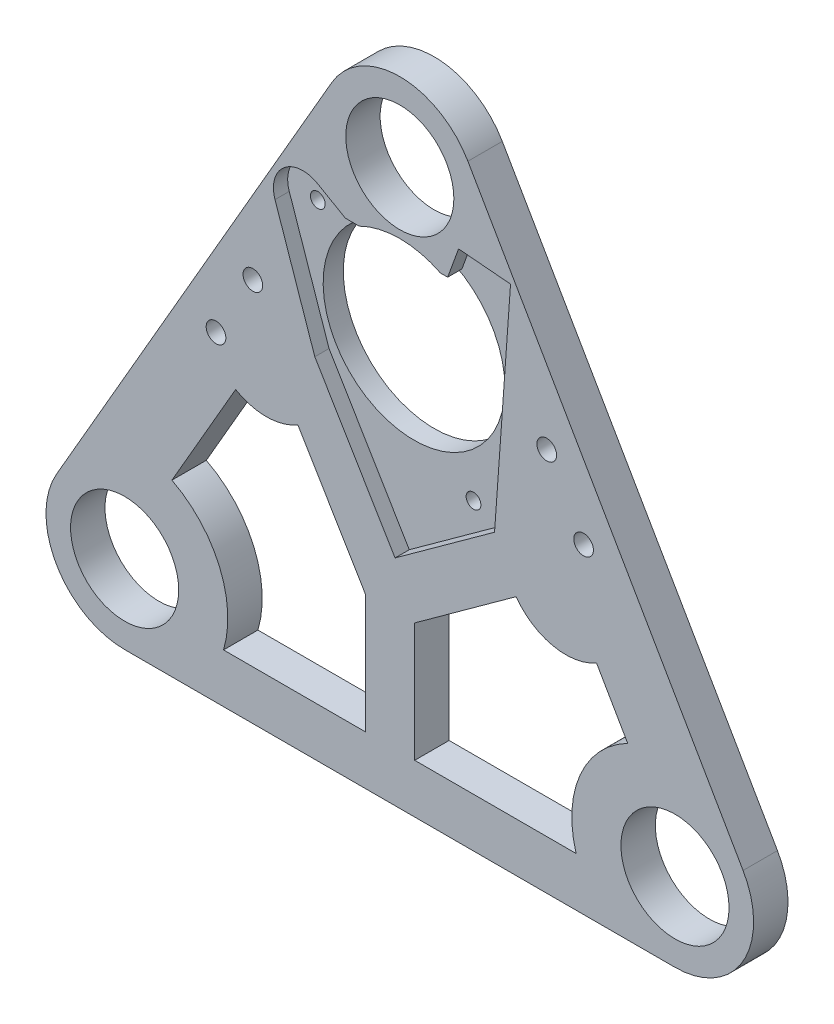
from build123d import *

# Parameters (mm, degrees)
SKETCH1_R           = 11
BOSS_EXTRUDE1_DEPTH = 7
SKETCH3_R           = 18.5
CUT_EXTRUDE1_DEPTH  = 8
CUT_EXTRUDE2_DEPTH  = 2.9
CUT_EXTRUDE3_DEPTH  = 8
SKETCH7_R           = 1.5
CUT_EXTRUDE4_DEPTH  = 5.1
SKETCH10_R          = 2
CUT_EXTRUDE5_DEPTH  = 8


with BuildPart() as part:
    # Sketch1 → Boss-Extrude1 (new body)
    with BuildSketch(Plane.XY):
        with BuildLine():
            Line((42.143593539, 104.994845224), (-13.856406461, 8))
            ThreePointArc((-13.856406461, 8), (-13.856406461, -8), (0, -16))
            Line((0, -16), (112, -16))
            ThreePointArc((112, -16), (125.856406461, -8), (125.856406461, 8))
            Line((125.856406461, 8), (69.856406461, 104.994845224))
            ThreePointArc((69.856406461, 104.994845224), (56, 112.994845224), (42.143593539, 104.994845224))
        make_face()
        Circle(SKETCH1_R, mode=Mode.SUBTRACT)
        with Locations((112, 0)):
            Circle(SKETCH1_R, mode=Mode.SUBTRACT)
        with Locations((56, 96.994845224)):
            Circle(SKETCH1_R, mode=Mode.SUBTRACT)
    extrude(amount=BOSS_EXTRUDE1_DEPTH)

    # Sketch3 → Cut-Extrude1 (cut, through all)
    with BuildSketch(Plane.XY.offset(7)):
        with Locations((56, 65.944845224)):
            Circle(SKETCH3_R)
    extrude(amount=-CUT_EXTRUDE1_DEPTH, mode=Mode.SUBTRACT)

    # Sketch4 → Cut-Extrude2 (cut)
    with BuildSketch(Plane.XY.offset(7)):
        with BuildLine():
            Line((44.91, 82.494845224), (65.74, 82.494845224))
            Line((65.74, 82.494845224), (67.963130932, 88.602847259))
            Line((67.963130932, 88.602847259), (78.535172855, 87.67791344))
            Line((78.535172855, 87.67791344), (75.282447168, 42.324405576))
            Line((75.282447168, 42.324405576), (55.030844768, 27.665872217))
            Line((55.030844768, 27.665872217), (38.701277947, 54.952961607))
            Line((38.701277947, 54.952961607), (30.604248297, 78.605405685))
            ThreePointArc((30.604248297, 78.605405685), (32.46849594, 85.181842037), (39.280834875, 85.744845224))
            Line((39.280834875, 85.744845224), (44.91, 82.494845224))
        make_face()
    extrude(amount=-CUT_EXTRUDE2_DEPTH, mode=Mode.SUBTRACT)

    # Sketch5 → Cut-Extrude3 (cut, through all)
    with BuildSketch(Plane.XY.offset(7)):
        with BuildLine():
            Line((22.59151766, 41.129656408), (9.622063078, 18.665902125))
            ThreePointArc((9.622063078, 18.665902125), (19.321434948, 8.226916285), (20.124611797, -6))
            Line((20.124611797, -6), (49.031546624, -6))
            Line((49.031546624, -6), (49.031546624, 18.216961725))
            Line((49.031546624, 18.216961725), (35.260372543, 41.228916805))
            ThreePointArc((35.260372543, 41.228916805), (28.939452074, 39.455357607), (22.59151766, 41.129656408))
        make_face()
        with BuildLine():
            Line((59.031546624, 18.216961725), (59.031546624, -6))
            Line((59.031546624, -6), (91.875388203, -6))
            ThreePointArc((91.875388203, -6), (92.678565052, 8.226916285), (102.377936922, 18.665902125))
            Line((102.377936922, 18.665902125), (96.035225677, 29.651800259))
            ThreePointArc((96.035225677, 29.651800259), (87.175426517, 28.252595389), (79.659424477, 33.147851127))
            Line((79.659424477, 33.147851127), (59.031546624, 18.216961725))
        make_face()
    extrude(amount=-CUT_EXTRUDE3_DEPTH, mode=Mode.SUBTRACT)

    # Sketch7 → Cut-Extrude4 (cut, through all)
    with BuildSketch(Plane.XY.offset(4.1)):
        with Locations((68.100893251, 42.839462205)):
            Circle(SKETCH7_R)
        with Locations((36.41, 79.994845224)):
            Circle(SKETCH7_R)
    extrude(amount=-CUT_EXTRUDE4_DEPTH, mode=Mode.SUBTRACT)

    # Sketch10 → Cut-Extrude5 (cut, through all)
    with BuildSketch(Plane.XY.offset(7)):
        with Locations((26.096327132, 62.200164484)):
            Circle(SKETCH10_R)
        with Locations((18.596327132, 49.209783427)):
            Circle(SKETCH10_R)
        with Locations((85.903672868, 62.200164484)):
            Circle(SKETCH10_R)
        with Locations((93.403672868, 49.209783427)):
            Circle(SKETCH10_R)
    extrude(amount=-CUT_EXTRUDE5_DEPTH, mode=Mode.SUBTRACT)


solid = part.part
